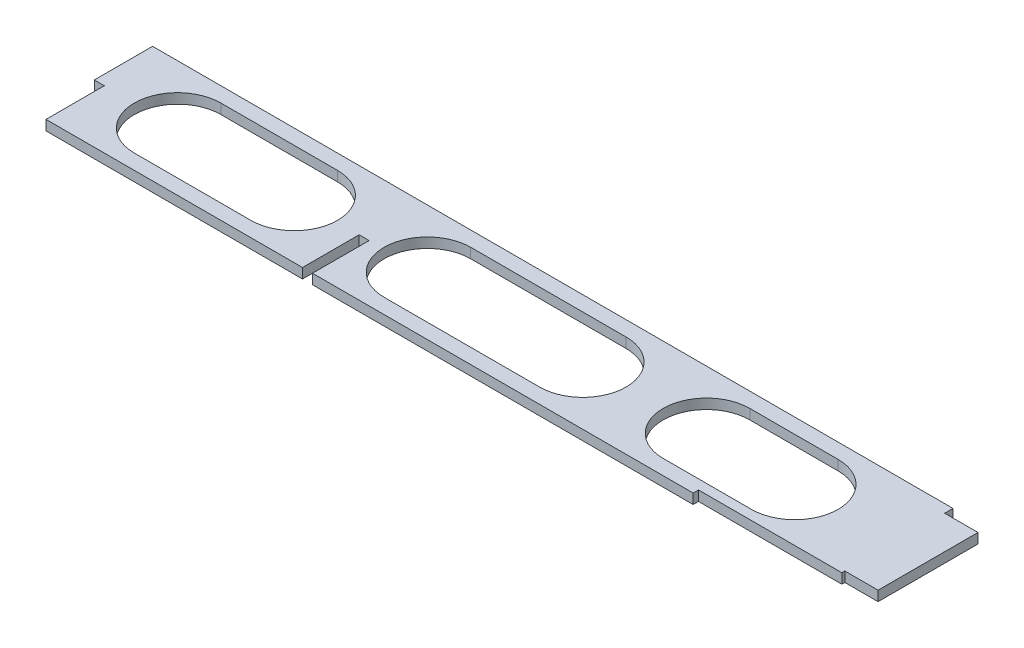
from build123d import *

# Parameters (mm, degrees)
SKETCH1_W               = 250.28
SKETCH1_H               = 35
BOSS_EXTRUDE1_DEPTH     = 3
SKETCH2_W               = 3
SKETCH2_H               = 17
CUT_EXTRUDE1_DEPTH      = 1
CUT_EXTRUDE1_DEPTH_BACK = 4
CUT_EXTRUDE3_DEPTH      = 4
SKETCH5_W               = 10
SKETCH5_H               = 2.5
CUT_EXTRUDE4_DEPTH      = 3
SKETCH6_W               = 3
SKETCH6_H               = 17.5
CUT_EXTRUDE5_DEPTH      = 10
SKETCH7_W               = 43
SKETCH7_H               = 3
CUT_EXTRUDE6_DEPTH      = 1.6


with BuildPart() as part:
    # Sketch1 → Boss-Extrude1 (new body)
    with BuildSketch(Plane(origin=(0, 0, 0), x_dir=(1, 0, 0), z_dir=(0, 1, 0))):
        with Locations((125.14, 0)):
            Rectangle(SKETCH1_W, SKETCH1_H)
    extrude(amount=BOSS_EXTRUDE1_DEPTH)

    # Sketch2 → Cut-Extrude1 (cut, two sides)
    with BuildSketch(Plane(origin=(0, 3, 0), x_dir=(1, 0, 0), z_dir=(0, 1, 0))) as cut_extrude1_sk:
        with Locations((81.5, -9)):
            Rectangle(SKETCH2_W, SKETCH2_H)
    extrude(amount=CUT_EXTRUDE1_DEPTH, mode=Mode.SUBTRACT)
    extrude(cut_extrude1_sk.sketch, amount=-CUT_EXTRUDE1_DEPTH_BACK, mode=Mode.SUBTRACT)

    # Sketch4 → Cut-Extrude3 (cut, through all)
    with BuildSketch(Plane(origin=(0, 3, 0), x_dir=(1, 0, 0), z_dir=(0, 1, 0))):
        with BuildLine():
            Line((183.762367309, 13), (210.28, 13))
            ThreePointArc((210.28, 13), (223.28, 0), (210.28, -13))
            Line((210.28, -13), (183.762367309, -13))
            ThreePointArc((183.762367309, -13), (170.762367309, 0), (183.762367309, 13))
        make_face()
        with BuildLine():
            Line((25, 13), (60, 13))
            ThreePointArc((60, 13), (73, 0), (60, -13))
            Line((60, -13), (25, -13))
            ThreePointArc((25, -13), (12, 0), (25, 13))
        make_face()
        with BuildLine():
            Line((100, 13), (146.655192757, 13))
            ThreePointArc((146.655192757, 13), (159.655192757, 0), (146.655192757, -13))
            Line((146.655192757, -13), (100, -13))
            ThreePointArc((100, -13), (87, 0), (100, 13))
        make_face()
    extrude(amount=-CUT_EXTRUDE3_DEPTH, mode=Mode.SUBTRACT)

    # Sketch5 → Cut-Extrude4 (cut)
    with BuildSketch(Plane(origin=(0, 3, 0), x_dir=(1, 0, 0), z_dir=(0, 1, 0))):
        with Locations((245.28, 16.25)):
            Rectangle(SKETCH5_W, SKETCH5_H)
        with Locations((245.28, -16.25)):
            Rectangle(SKETCH5_W, SKETCH5_H)
    extrude(amount=-CUT_EXTRUDE4_DEPTH, mode=Mode.SUBTRACT)

    # Sketch6 → Cut-Extrude5 (cut)
    with BuildSketch(Plane(origin=(0, 3, 0), x_dir=(1, 0, 0), z_dir=(0, 1, 0))):
        with Locations((1.5, -8.75)):
            Rectangle(SKETCH6_W, SKETCH6_H)
    extrude(amount=-CUT_EXTRUDE5_DEPTH, mode=Mode.SUBTRACT)

    # Sketch7 → Cut-Extrude6 (cut)
    with BuildSketch(Plane.XY.offset(17.5)):
        with Locations((218.78, 1.5)):
            Rectangle(SKETCH7_W, SKETCH7_H)
    extrude(amount=-CUT_EXTRUDE6_DEPTH, mode=Mode.SUBTRACT)


solid = part.part
